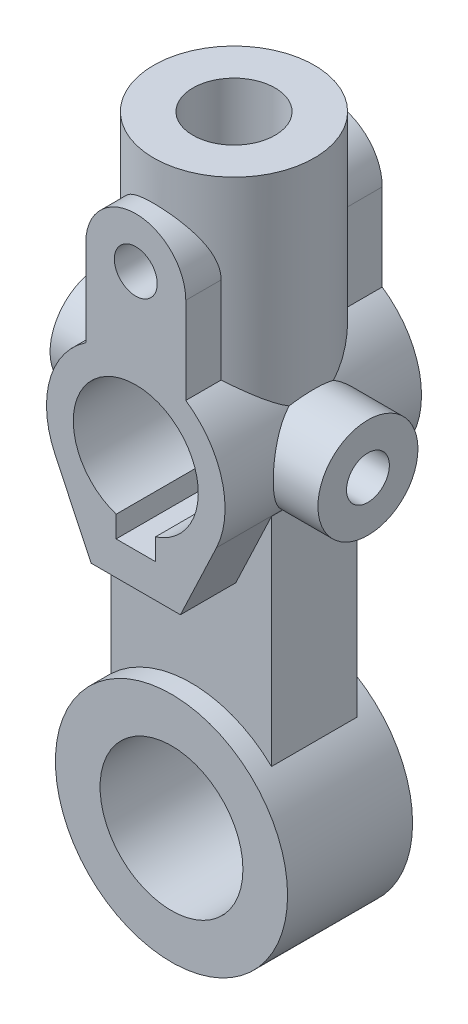
from build123d import *

# Parameters (mm, degrees)
SALIENTE_EXTRUIR3_DEPTH    = 27.5
CROQUIS3_R                 = 22.5
SALIENTE_EXTRUIR4_DEPTH    = 70
CROQUIS4_W                 = 45
CROQUIS4_H                 = 24
SALIENTE_EXTRUIR5_DEPTH    = 95
CROQUIS5_R                 = 32.5
SALIENTE_EXTRUIR6_DEPTH    = 17.5
CROQUIS6_R                 = 14
SALIENTE_EXTRUIR7_DEPTH    = 37.5
CROQUIS7_R                 = 6
CORTAR_EXTRUIR1_DEPTH      = 28.5000001
CORTAR_EXTRUIR1_DEPTH_BACK = 28.5000001
CROQUIS8_R                 = 6
CORTAR_EXTRUIR2_DEPTH      = 76.0000001
CROQUIS9_R                 = 20
CORTAR_EXTRUIR3_DEPTH      = 46.0000001
CORTAR_EXTRUIR4_REACH      = 199.5
CORTAR_EXTRUIR4_END_RADIUS = 17.5
CROQUIS10_R                = 11.5


with BuildPart() as part:
    # Croquis1 → Saliente-Extruir3 (new body, symmetric)
    with BuildSketch(Plane.XY):
        with BuildLine():
            Line((14, 20.712315177), (14, 45))
            ThreePointArc((14, 45), (0, 59), (-14, 45))
            Line((-14, 45), (-14, 20.712315177))
            ThreePointArc((-14, 20.712315177), (-24.114680724, 6.594101422), (-22.59139561, -10.70648609))
            Line((-22.59139561, -10.70648609), (-12.5, -32))
            Line((-12.5, -32), (12.5, -32))
            Line((12.5, -32), (22.59139561, -10.70648609))
            ThreePointArc((22.59139561, -10.70648609), (24.114680724, 6.594101422), (14, 20.712315177))
        make_face()
    extrude(amount=SALIENTE_EXTRUIR3_DEPTH, both=True)

    # Croquis3 → Saliente-Extruir4 (add)
    with BuildSketch(Plane(origin=(0, 0, 0), x_dir=(1, 0, 0), z_dir=(0, 1, 0))):
        with Locations(Location((0, 0, 0), (0, 0, 51.521405051))):  # turned: the seam where the file's is
            Circle(CROQUIS3_R)
    extrude(amount=SALIENTE_EXTRUIR4_DEPTH)

    # Croquis4 → Saliente-Extruir5 (add)
    with BuildSketch(Plane(origin=(0, 0, 0), x_dir=(1, 0, 0), z_dir=(0, 1, 0))):
        Rectangle(CROQUIS4_W, CROQUIS4_H)
    extrude(amount=-SALIENTE_EXTRUIR5_DEPTH)

    # Croquis5 → Saliente-Extruir6 (add, symmetric)
    with BuildSketch(Plane.XY):
        with Locations((0, -95)):
            Circle(CROQUIS5_R)
    extrude(amount=SALIENTE_EXTRUIR6_DEPTH, both=True)

    # Croquis6 → Saliente-Extruir7 (add, symmetric)
    with BuildSketch(Plane(origin=(0, 0, 0), x_dir=(0, 0, -1), z_dir=(1, 0, 0))):
        with Locations(Location((0, 0, 0), (0, 0, 229.884667682))):  # turned: the seam where the file's is
            Circle(CROQUIS6_R)
    extrude(amount=SALIENTE_EXTRUIR7_DEPTH, both=True)

    # Croquis7 → Cortar-Extruir1 (cut, two sides)
    with BuildSketch(Plane.XY) as cortar_extruir1_sk:
        with Locations((0, 45)):
            Circle(CROQUIS7_R)
        with BuildLine():
            Line((5.5, -22.613247726), (5.5, -16.613247726))
            ThreePointArc((5.5, -16.613247726), (0, 17.5), (-5.5, -16.613247726))
            Line((-5.5, -16.613247726), (-5.5, -22.613247726))
            Line((-5.5, -22.613247726), (5.5, -22.613247726))
        make_face()
    extrude(amount=CORTAR_EXTRUIR1_DEPTH, mode=Mode.SUBTRACT)
    extrude(cortar_extruir1_sk.sketch, amount=-CORTAR_EXTRUIR1_DEPTH_BACK, mode=Mode.SUBTRACT)

    # Croquis8 → Cortar-Extruir2 (cut, through all)
    with BuildSketch(Plane(origin=(37.5, 0, 0), x_dir=(0, 0, -1), z_dir=(1, 0, 0))):
        Circle(CROQUIS8_R)
    extrude(amount=-CORTAR_EXTRUIR2_DEPTH, mode=Mode.SUBTRACT)

    # Croquis9 → Cortar-Extruir3 (cut, through all)
    with BuildSketch(Plane.XY.offset(17.5)):
        with Locations((0, -95)):
            Circle(CROQUIS9_R)
    extrude(amount=-CORTAR_EXTRUIR3_DEPTH, mode=Mode.SUBTRACT)

    # Cortar-Extruir4: up to this cylinder (the profile starts outside it)
    cortar_extruir4_end = Plane(origin=(0, 0, 0), z_dir=(0, 0, 1)) * Cylinder(CORTAR_EXTRUIR4_END_RADIUS, 435, mode=Mode.PRIVATE)
    # Croquis10 → Cortar-Extruir4 (cut, up to the surface)
    with BuildSketch(Plane(origin=(0, 70, 0), x_dir=(1, 0, 0), z_dir=(0, 1, 0)), mode=Mode.PRIVATE) as cortar_extruir4_sk1:
        with Locations(Location((0, 0, 0), (0, 0, 270))):  # turned: the seam where the file's is
            Circle(CROQUIS10_R)
    cortar_extruir4_tool1 = extrude(cortar_extruir4_sk1.sketch, amount=-CORTAR_EXTRUIR4_REACH, mode=Mode.PRIVATE) - cortar_extruir4_end
    add(cortar_extruir4_tool1.solids().sort_by_distance((0, 70, 0))[0], mode=Mode.SUBTRACT)


solid = part.part
